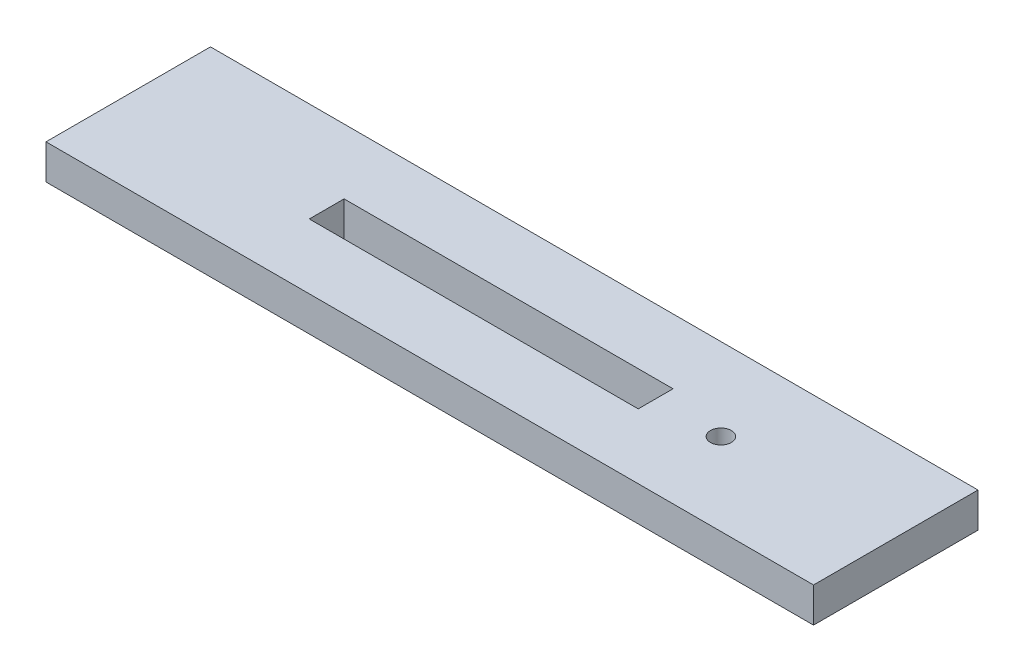
from build123d import *

# Parameters (mm, degrees)
SKETCH1_W           = 140
SKETCH1_H           = 30
SKETCH1_R           = 1.9
SKETCH1_W_2         = 60
SKETCH1_H_2         = 6.35
BOSS_EXTRUDE1_DEPTH = 6.35


with BuildPart() as part:
    # Sketch1 → Boss-Extrude1 (new body)
    with BuildSketch(Plane(origin=(0, 0, 0), x_dir=(1, 0, 0), z_dir=(0, 1, 0))):
        with Locations((0, -2.433171599)):
            Rectangle(SKETCH1_W, SKETCH1_H)
        with Locations((38.1, -2.433171599)):
            Circle(SKETCH1_R, mode=Mode.SUBTRACT)
        with Locations((-3.8, -2.433171599)):
            Rectangle(SKETCH1_W_2, SKETCH1_H_2, mode=Mode.SUBTRACT)
    extrude(amount=BOSS_EXTRUDE1_DEPTH)


solid = part.part
